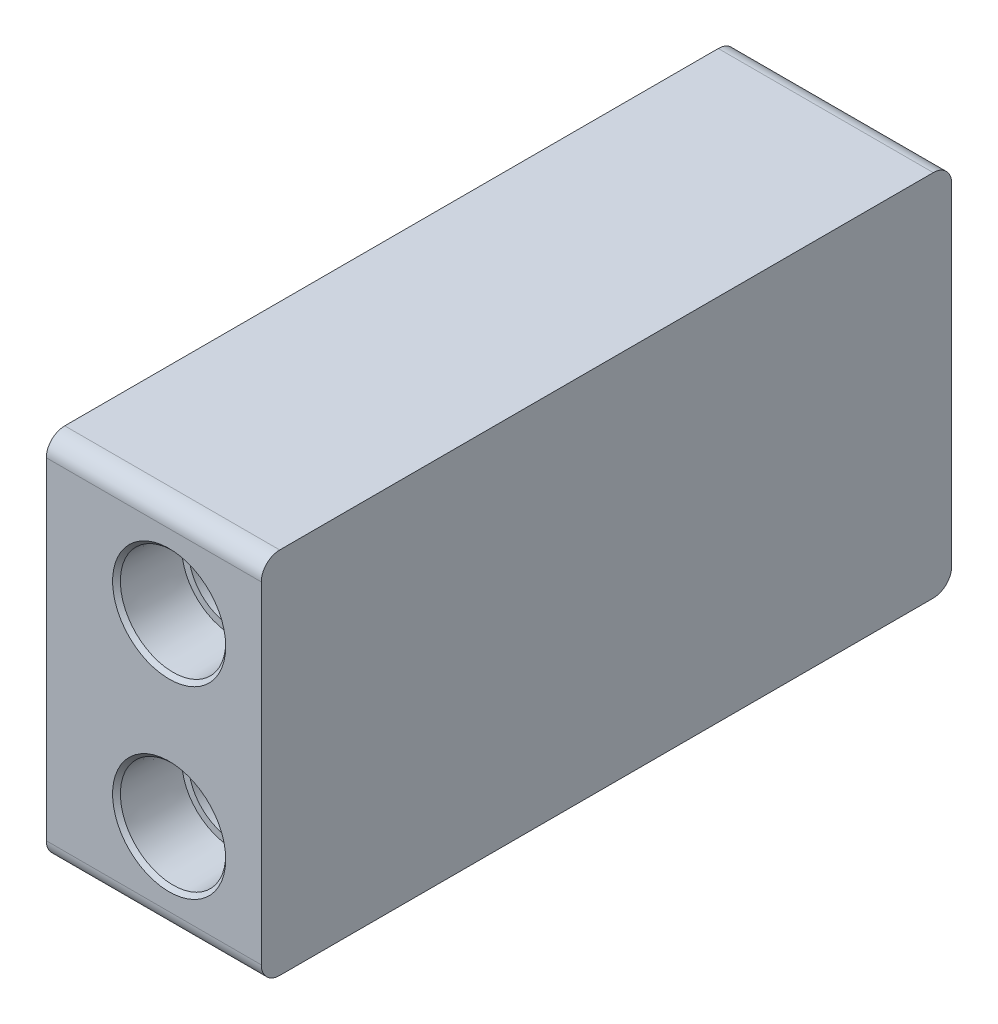
from build123d import *

# Parameters (mm, degrees)
BLOCK_SKETCH_W                                 = 112.406774914
BLOCK_SKETCH_H                                 = 60
BLOCK_DEPTH                                    = 17.5
F_3_8_NPT_FLOW_CONNECTOR_AT_2_COUNT            = 2
F_3_8_NPT_FLOW_CONNECTOR_AT_2_PITCH            = 30
F_1_8_NPT_PRESSURE_SENSOR_CONNECTOR_AT_2_COUNT = 2
F_1_8_NPT_PRESSURE_SENSOR_CONNECTOR_AT_2_PITCH = 42.2
F_1_8_NPT_PRESSURE_SENSOR_CONNECTOR_AT_3_COUNT = 2
F_1_8_NPT_PRESSURE_SENSOR_CONNECTOR_AT_3_PITCH = 51.776828794
F_1_8_NPT_PRESSURE_SENSOR_CONNECTOR_AT_4_COUNT = 2
F_1_8_NPT_PRESSURE_SENSOR_CONNECTOR_AT_4_PITCH = 30
PRESSURE_SENSOR_HOLE_REACH                     = 37
SKETCH11_R                                     = 1.6
M8X1_0_TAPPED_HOLE1_D                          = 7
M10X1_0_TAPPED_HOLE1_D                         = 9
ROUNDED_EDGES_R                                = 3


with BuildPart() as part:
    # block_sketch → block (new body, symmetric)
    with BuildSketch(Plane(origin=(0, 0, 0), x_dir=(0, 0, -1), z_dir=(1, 0, 0))):
        Rectangle(BLOCK_SKETCH_W, BLOCK_SKETCH_H)
    extrude(amount=BLOCK_DEPTH, both=True)

    # Sketch6 → 3/8 NPT_flow_connector (revolve, cut)
    with BuildSketch(Plane(origin=(2.5, 15, 56.203387457), x_dir=(0, -1, 0), z_dir=(1, 0, 0))):
        Polygon((0, 0), (0, 21.668582582), (7.1374, 17.38), (7.1374, 10.33), (8.282218717, 10.33), (8.5725, 0.635), (9.2075, 0), align=None)
    f_3_8_npt_flow_connector = revolve(axis=Axis((2.5, 15, 62.553387457), (0, 0, -1)), mode=Mode.SUBTRACT)

    # 3/8 NPT_flow_connector at 2: 3/8 NPT_flow_connector ×2
    with Locations(*[(0, -i * F_3_8_NPT_FLOW_CONNECTOR_AT_2_PITCH, 0) for i in range(1, F_3_8_NPT_FLOW_CONNECTOR_AT_2_COUNT)]):
        add(f_3_8_npt_flow_connector, mode=Mode.SUBTRACT)

    # Sketch15 → M8_flow_channel (revolve, cut)
    with BuildSketch(Plane(origin=(2.5, -15, 56.203387457), x_dir=(0, -1, 0), z_dir=(1, 0, 0))):
        Polygon((0, 0), (0, 42.018852388), (6.35, 38.203387457), (6.35, 0), align=None)
    m8_flow_channel = revolve(axis=Axis((2.5, -15, 62.553387457), (0, 0, -1)), mode=Mode.SUBTRACT)

    # Sketch20 → M10_flow_channel (revolve, cut)
    with BuildSketch(Plane(origin=(2.5, 15, 56.203387457), x_dir=(0, -1, 0), z_dir=(1, 0, 0))):
        Polygon((0, 0), (0, 42.018852388), (6.35, 38.203387457), (6.35, 0), align=None)
    m10_flow_channel = revolve(axis=Axis((2.5, 15, 62.553387457), (0, 0, -1)), mode=Mode.SUBTRACT)

    # flow_mirror: M10_flow_channel, 3/8 NPT_flow_connector, M8_flow_channel across plane
    add(m10_flow_channel.mirror(Plane.XY), mode=Mode.SUBTRACT)
    add(f_3_8_npt_flow_connector.mirror(Plane.XY), mode=Mode.SUBTRACT)
    add(m8_flow_channel.mirror(Plane.XY), mode=Mode.SUBTRACT)

    # flow_mirror copy 1 sketch → flow_mirror copy 1 (revolve, cut)
    with BuildSketch(Plane(origin=(2.5, -15, -56.203387457), x_dir=(0, -1, 0), z_dir=(1, 0, 0))):
        Polygon((0, 0), (0, -21.668582582), (7.1374, -17.38), (7.1374, -10.33), (8.282218717, -10.33), (8.5725, -0.635), (9.2075, 0), align=None)
    revolve(axis=Axis((2.5, -15, -62.553387457), (0, 0, -1)), mode=Mode.SUBTRACT)

    # Sketch4 → 1/8 NPT_pressure_sensor_connector (revolve, cut)
    with BuildSketch(Plane(origin=(-17.5, -15, 21.1), x_dir=(0, 0, 1), z_dir=(0, 1, 0))):
        Polygon((0, 0), (0, 14.153468714), (4.2164, 11.62), (4.2164, 6.92), (4.955191683, 6.92), (5.143373, 0.635), (5.778373, 0), align=None)
    f_1_8_npt_pressure_sensor_connector = revolve(axis=Axis((-23.85, -15, 21.1), (1, 0, 0)), mode=Mode.SUBTRACT)

    # 1/8 NPT_pressure_sensor_connector at 2: 1/8 NPT_pressure_sensor_connector ×2
    with Locations(*[(0, 0, -i * F_1_8_NPT_PRESSURE_SENSOR_CONNECTOR_AT_2_PITCH) for i in range(1, F_1_8_NPT_PRESSURE_SENSOR_CONNECTOR_AT_2_COUNT)]):
        add(f_1_8_npt_pressure_sensor_connector, mode=Mode.SUBTRACT)

    # 1/8 NPT_pressure_sensor_connector at 3: 1/8 NPT_pressure_sensor_connector ×2
    with Locations(*[Vector(0, 0.579409761, -0.815036397) * (i * F_1_8_NPT_PRESSURE_SENSOR_CONNECTOR_AT_3_PITCH) for i in range(1, F_1_8_NPT_PRESSURE_SENSOR_CONNECTOR_AT_3_COUNT)]):
        add(f_1_8_npt_pressure_sensor_connector, mode=Mode.SUBTRACT)

    # 1/8 NPT_pressure_sensor_connector at 4: 1/8 NPT_pressure_sensor_connector ×2
    with Locations(*[(0, i * F_1_8_NPT_PRESSURE_SENSOR_CONNECTOR_AT_4_PITCH, 0) for i in range(1, F_1_8_NPT_PRESSURE_SENSOR_CONNECTOR_AT_4_COUNT)]):
        add(f_1_8_npt_pressure_sensor_connector, mode=Mode.SUBTRACT)

    # Sketch11 → pressure_sensor_hole (cut, up to next)
    with BuildSketch(Plane(origin=(-17.5, 14.596917944, 0), x_dir=(0, -1, 0), z_dir=(1, 0, 0)), mode=Mode.PRIVATE) as pressure_sensor_hole_sk1:
        with Locations((29.596917944, 21.1)):
            Circle(SKETCH11_R)
    pressure_sensor_hole_tool1 = extrude(pressure_sensor_hole_sk1.sketch, amount=PRESSURE_SENSOR_HOLE_REACH, mode=Mode.PRIVATE) & part.part
    add(pressure_sensor_hole_tool1.solids().sort_by_distance((-17.5, -15, -21.1))[0], mode=Mode.SUBTRACT)
    # Sketch11 → pressure_sensor_hole (cut, up to next)
    with BuildSketch(Plane(origin=(-17.5, 14.596917944, 0), x_dir=(0, -1, 0), z_dir=(1, 0, 0)), mode=Mode.PRIVATE) as pressure_sensor_hole_sk2:
        with Locations((29.596917944, -21.1)):
            Circle(SKETCH11_R)
    pressure_sensor_hole_tool2 = extrude(pressure_sensor_hole_sk2.sketch, amount=PRESSURE_SENSOR_HOLE_REACH, mode=Mode.PRIVATE) & part.part
    add(pressure_sensor_hole_tool2.solids().sort_by_distance((-17.5, -15, 21.1))[0], mode=Mode.SUBTRACT)
    # Sketch11 → pressure_sensor_hole (cut, up to next)
    with BuildSketch(Plane(origin=(-17.5, 14.596917944, 0), x_dir=(0, -1, 0), z_dir=(1, 0, 0)), mode=Mode.PRIVATE) as pressure_sensor_hole_sk3:
        with Locations((-0.403082056, 21.1)):
            Circle(SKETCH11_R)
    pressure_sensor_hole_tool3 = extrude(pressure_sensor_hole_sk3.sketch, amount=PRESSURE_SENSOR_HOLE_REACH, mode=Mode.PRIVATE) & part.part
    add(pressure_sensor_hole_tool3.solids().sort_by_distance((-17.5, 15, -21.1))[0], mode=Mode.SUBTRACT)
    # Sketch11 → pressure_sensor_hole (cut, up to next)
    with BuildSketch(Plane(origin=(-17.5, 14.596917944, 0), x_dir=(0, -1, 0), z_dir=(1, 0, 0)), mode=Mode.PRIVATE) as pressure_sensor_hole_sk4:
        with Locations((-0.403082056, -21.1)):
            Circle(SKETCH11_R)
    pressure_sensor_hole_tool4 = extrude(pressure_sensor_hole_sk4.sketch, amount=PRESSURE_SENSOR_HOLE_REACH, mode=Mode.PRIVATE) & part.part
    add(pressure_sensor_hole_tool4.solids().sort_by_distance((-17.5, 15, 21.1))[0], mode=Mode.SUBTRACT)

    # M8x1.0 Tapped Hole1 (through all)
    with Locations(Plane.XY.offset(56.203387457)):
        with Locations((2.5, -15)):
            Hole(M8X1_0_TAPPED_HOLE1_D / 2)

    # M10x1.0 Tapped Hole1 (through all)
    with Locations(Plane.XY.offset(56.203387457)):
        with Locations((2.5, 15)):
            Hole(M10X1_0_TAPPED_HOLE1_D / 2)

    # rounded_edges
    rounded_edges_edges = [part.edges().sort_by_distance(p)[0] for p in [
        (0, 30, 56.203387457),
        (0, 30, -56.203387457),
        (0, -30, -56.203387457),
        (0, -30, 56.203387457),
    ]]
    fillet(rounded_edges_edges, radius=ROUNDED_EDGES_R)


solid = part.part
